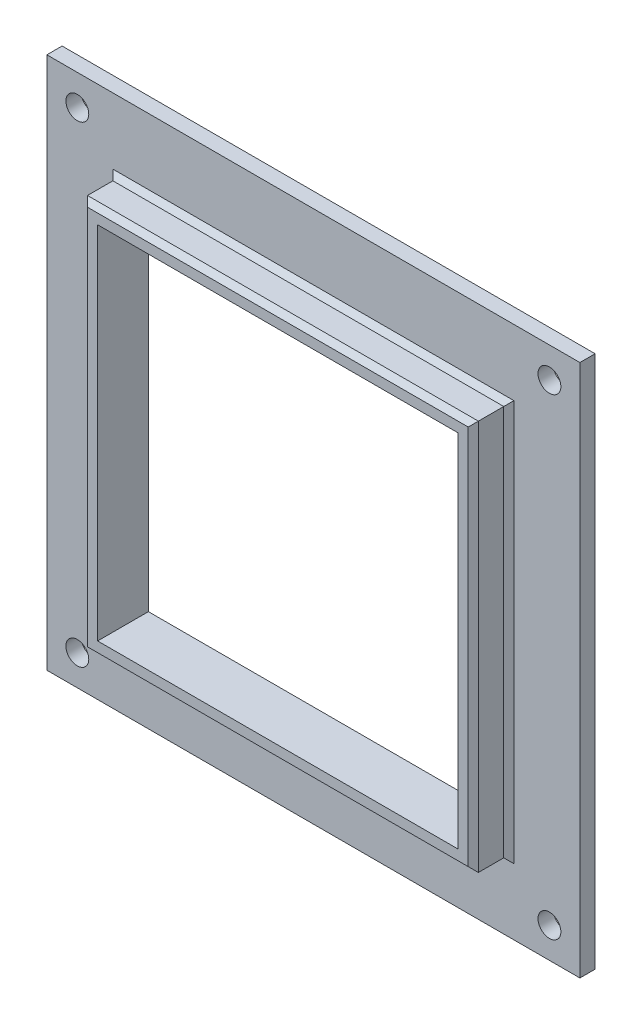
from build123d import *

# Parameters (mm, degrees)
SKETCH_1_W          = 105
SKETCH_1_H          = 105
SKETCH_1_W_2        = 71
SKETCH_1_H_2        = 71
EXTRUDE_1_DEPTH     = 3
SKETCH_2_W          = 77
SKETCH_2_H          = 77
SKETCH_2_W_2        = 71
SKETCH_2_H_2        = 71
EXTRUDE_2_DEPTH     = 7
CHAMFER_1_SIZE      = 1
SKETCH_4_R          = 2.25
CUT_EXTRUDE_1_DEPTH = 4


with BuildPart() as part:
    # Эскиз1 → Бобышка-Вытянуть1 (new body)
    with BuildSketch(Plane.XY):
        with Locations((35.5, 35.5)):
            Rectangle(SKETCH_1_W, SKETCH_1_H)
        with Locations((35.5, 35.5)):
            Rectangle(SKETCH_1_W_2, SKETCH_1_H_2, mode=Mode.SUBTRACT)
    extrude(amount=EXTRUDE_1_DEPTH)

    # Эскиз2 → Бобышка-Вытянуть2 (add)
    with BuildSketch(Plane.XY.offset(3)):
        with Locations((35.5, 35.5)):
            Rectangle(SKETCH_2_W, SKETCH_2_H)
        with Locations((35.5, 35.5)):
            Rectangle(SKETCH_2_W_2, SKETCH_2_H_2, mode=Mode.SUBTRACT)
    extrude(amount=EXTRUDE_2_DEPTH)

    # Фаска1
    chamfer_1_edges = [part.edges().sort_by_distance(p)[0] for p in [
        (-3, 35.5, 10),
        (35.5, -3, 10),
        (74, 35.5, 10),
        (35.5, 74, 10),
        (-3, 35.5, 3),
        (35.5, -3, 3),
        (74, 35.5, 3),
        (35.5, 74, 3),
    ]]
    chamfer(chamfer_1_edges, length=CHAMFER_1_SIZE)

    # Эскиз4 → Вырез-Вытянуть1 (cut, through all)
    with BuildSketch(Plane.XY.offset(3)):
        with Locations((-11, 82)):
            Circle(SKETCH_4_R)
        with Locations((82, 82)):
            Circle(SKETCH_4_R)
        with Locations((82, -11)):
            Circle(SKETCH_4_R)
        with Locations((-11, -11)):
            Circle(SKETCH_4_R)
    extrude(amount=-CUT_EXTRUDE_1_DEPTH, mode=Mode.SUBTRACT)


solid = part.part
